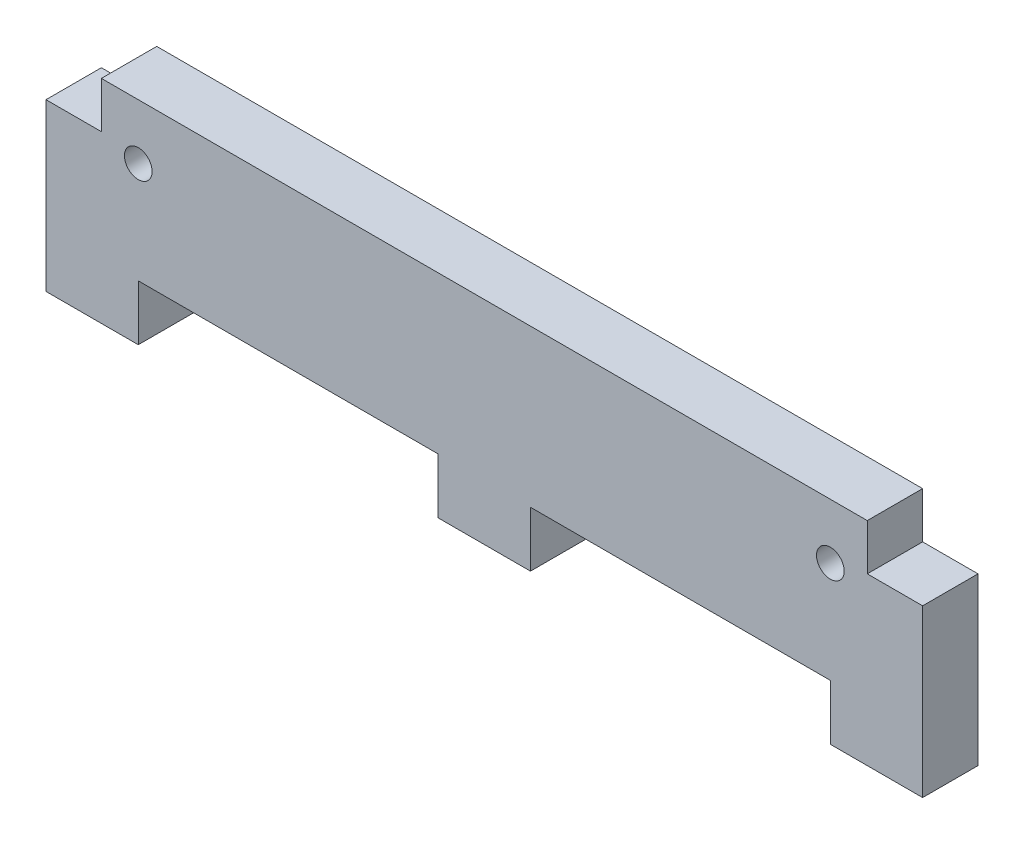
from build123d import *

# Parameters (mm, degrees)
SKETCH1_W           = 95
SKETCH1_H           = 23
BOSS_EXTRUDE1_DEPTH = 6
SKETCH2_W           = 32.5
SKETCH2_H           = 6
CUT_EXTRUDE1_DEPTH  = 7
SKETCH4_R           = 1.5
CUT_EXTRUDE2_DEPTH  = 7
SKETCH5_W           = 6
SKETCH5_H           = 5
CUT_EXTRUDE3_DEPTH  = 7


with BuildPart() as part:
    # Sketch1 → Boss-Extrude1 (new body)
    with BuildSketch(Plane.XY):
        with Locations((47.5, 11.5)):
            Rectangle(SKETCH1_W, SKETCH1_H)
    extrude(amount=BOSS_EXTRUDE1_DEPTH)

    # Sketch2 → Cut-Extrude1 (cut, through all)
    with BuildSketch(Plane.XY.offset(6)):
        with Locations((26.25, 3)):
            Rectangle(SKETCH2_W, SKETCH2_H)
        with Locations((68.75, 3)):
            Rectangle(SKETCH2_W, SKETCH2_H)
    extrude(amount=-CUT_EXTRUDE1_DEPTH, mode=Mode.SUBTRACT)

    # Sketch4 → Cut-Extrude2 (cut, through all)
    with BuildSketch(Plane.XY.offset(6)):
        with Locations((10, 17)):
            Circle(SKETCH4_R)
        with Locations((85, 17)):
            Circle(SKETCH4_R)
    extrude(amount=-CUT_EXTRUDE2_DEPTH, mode=Mode.SUBTRACT)

    # Sketch5 → Cut-Extrude3 (cut, through all)
    with BuildSketch(Plane.XY.offset(6)):
        with Locations((3, 20.5)):
            Rectangle(SKETCH5_W, SKETCH5_H)
        with Locations((92, 20.5)):
            Rectangle(SKETCH5_W, SKETCH5_H)
    extrude(amount=-CUT_EXTRUDE3_DEPTH, mode=Mode.SUBTRACT)


solid = part.part
